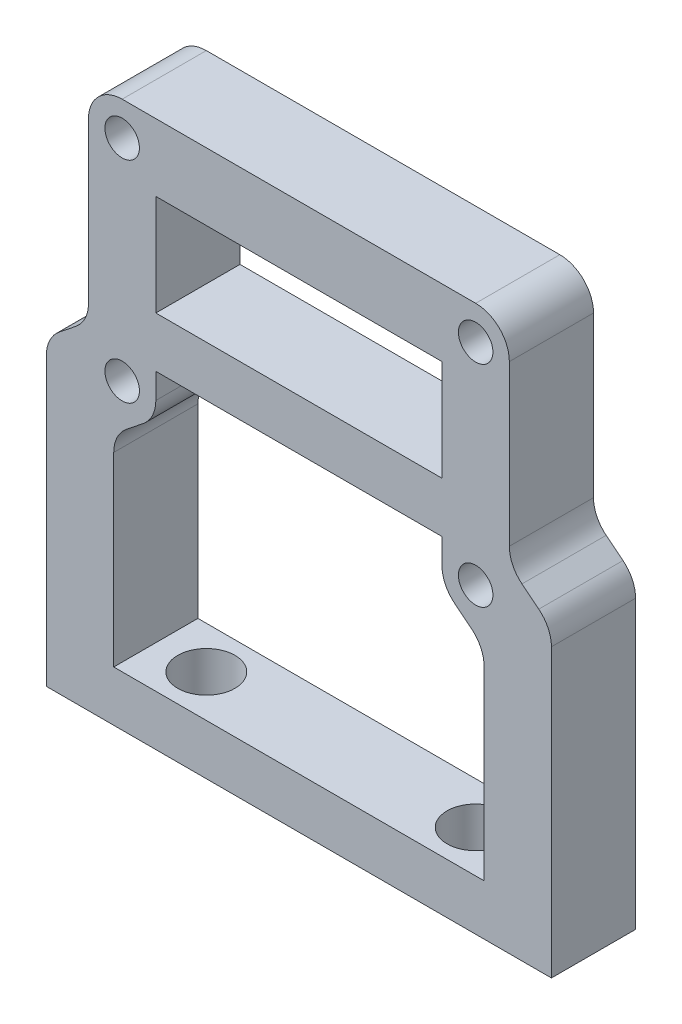
from build123d import *

# Parameters (mm, degrees)
SKETCH1_R                = 0.25
SKETCH1_W                = 17
SKETCH1_H                = 6
BOSS_EXTRUDE1_DEPTH      = 5
FILLET1_R                = 2
M2_5X0_45_TAPPED_HOLE1_D = 2.05
M3_CLEARANCE_HOLE1_D     = 3.4
M3_CLEARANCE_HOLE1_DEPTH = 3


with BuildPart() as part:
    # Sketch1 → Boss-Extrude1 (new body)
    with BuildSketch(Plane.XY):
        Polygon((-15, 0), (15, 0), (15, 18), (12.5, 20), (12.5, 32.461249695), (-12.5, 32.461249695), (-12.5, 20), (-15, 18), align=None)
        with Locations((-10.5, 30.461249695)):
            Circle(SKETCH1_R, mode=Mode.SUBTRACT)
        with Locations((-10.5, 17.961249695)):
            Circle(SKETCH1_R, mode=Mode.SUBTRACT)
        with Locations((10.5, 30.461249695)):
            Circle(SKETCH1_R, mode=Mode.SUBTRACT)
        with Locations((10.5, 17.961249695)):
            Circle(SKETCH1_R, mode=Mode.SUBTRACT)
        Polygon((-11, 15), (-8.5, 17), (-8.5, 19.461249695), (8.5, 19.461249695), (8.5, 17), (11, 15), (11, 3), (-11, 3), align=None, mode=Mode.SUBTRACT)
        with Locations((0, 25.461249695)):
            Rectangle(SKETCH1_W, SKETCH1_H, mode=Mode.SUBTRACT)
    extrude(amount=BOSS_EXTRUDE1_DEPTH)

    # Fillet1
    fillet1_edges = [part.edges().sort_by_distance(p)[0] for p in [
        (-15, 18, 2.5),
        (-12.5, 20, 2.5),
        (-12.5, 32.461249695, 2.5),
        (12.5, 32.461249695, 2.5),
        (12.5, 20, 2.5),
        (15, 18, 2.5),
        (-11, 15, 2.5),
        (11, 15, 2.5),
        (8.5, 17, 2.5),
        (-8.5, 17, 2.5),
    ]]
    fillet(fillet1_edges, radius=FILLET1_R)

    # M2.5x0.45 Tapped Hole1 (through all)
    with Locations(Plane.XY.offset(5)):
        with Locations((-10.5, 17.961249695), (10.5, 30.461249695), (10.5, 17.961249695), (-10.5, 30.461249695)):
            Hole(M2_5X0_45_TAPPED_HOLE1_D / 2)

    # M3 Clearance Hole1
    with Locations(Plane(origin=(0, 0, 0), x_dir=(-1, 0, 0), z_dir=(0, -1, 0))):
        with Locations((8, -2.5), (-8, -2.5)):
            Hole(M3_CLEARANCE_HOLE1_D / 2, depth=M3_CLEARANCE_HOLE1_DEPTH)


solid = part.part
